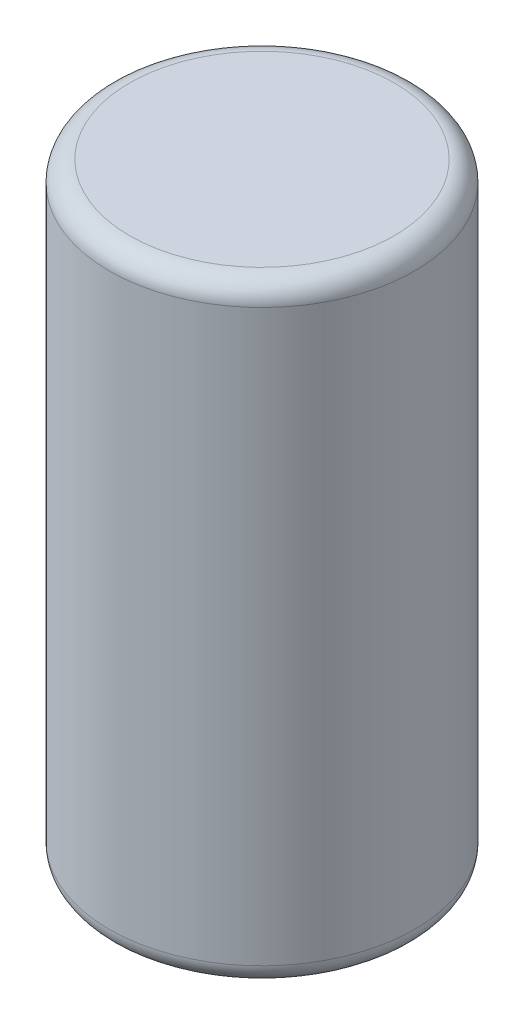
from build123d import *

# Parameters (mm, degrees)
ESQUISSE1_R        = 1.5
BOSS_EXTRU_1_DEPTH = 6
CONG_1_R           = 0.2


with BuildPart() as part:
    # Esquisse1 → Boss.-Extru.1 (new body)
    with BuildSketch(Plane(origin=(0, 0, 0), x_dir=(1, 0, 0), z_dir=(0, 1, 0))):
        Circle(ESQUISSE1_R)
    extrude(amount=BOSS_EXTRU_1_DEPTH)

    # Congé1
    cong_1_edges = [part.edges().sort_by_distance(p)[0] for p in [
        (-1.5, 0, 0),
        (-1.5, 6, 0),
    ]]
    fillet(cong_1_edges, radius=CONG_1_R)


solid = part.part
